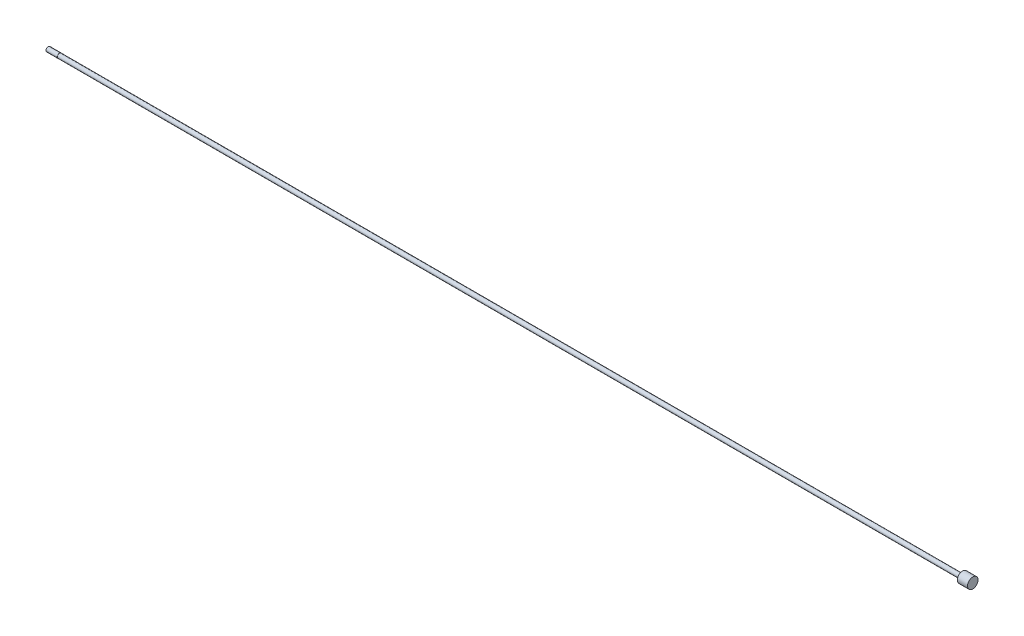
from build123d import *

# Parameters (mm, degrees)
SKETCH3_W = 0.254
SKETCH3_H = 0.508


with BuildPart() as part:
    # Sketch1 → Revolve1 (revolve)
    with BuildSketch(Plane.XY):
        Polygon((0, 0), (0, 2.3749), (969.9752, 2.3749), (969.9752, 5.61975), (980.9988, 5.61975), (980.9988, 0), align=None)
    revolve(axis=Axis((980.9988, 0, 0), (-1, 0, 0)))

    # Sketch2 → Revolve2 (revolve)
    with BuildSketch(Plane.XY):
        Polygon((-12.7, 0), (-12.7, 1.94056), (-12.22756, 2.413), (0, 2.413), (0, 0), align=None)
    revolve(axis=Axis((0, 0, 0), (-1, 0, 0)))

    # Sketch3 → Cut-Revolve1 (revolve, cut)
    with BuildSketch(Plane.XY):
        with Locations((-0.127, 2.413)):
            Rectangle(SKETCH3_W, SKETCH3_H)
    revolve(axis=Axis((0, 0, 0), (-1, 0, 0)), mode=Mode.SUBTRACT)


solid = part.part
